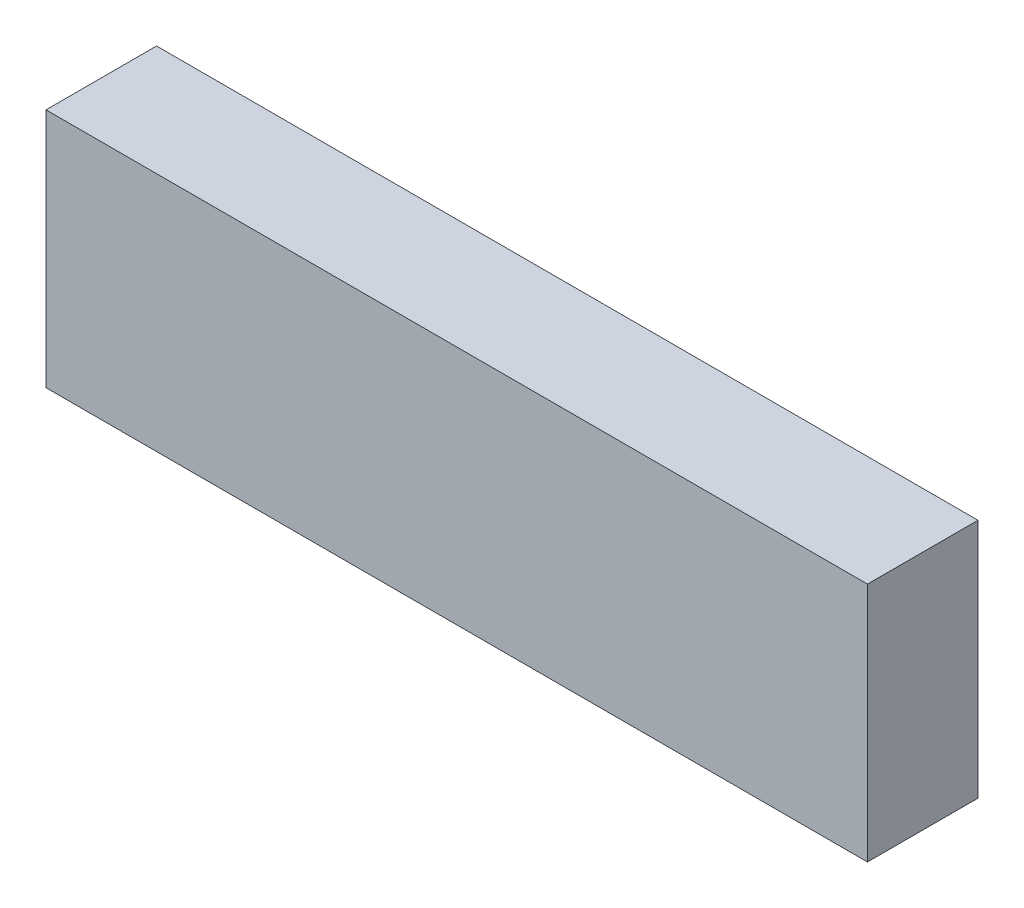
from build123d import *

# Parameters (mm, degrees)
SKETCH1_W           = 59.1693
SKETCH1_H           = 17.3355
BOSS_EXTRUDE1_DEPTH = 7.9629


with BuildPart() as part:
    # Sketch1 → Boss-Extrude1 (new body)
    with BuildSketch(Plane.XY):
        Rectangle(SKETCH1_W, SKETCH1_H)
    extrude(amount=BOSS_EXTRUDE1_DEPTH)


solid = part.part
